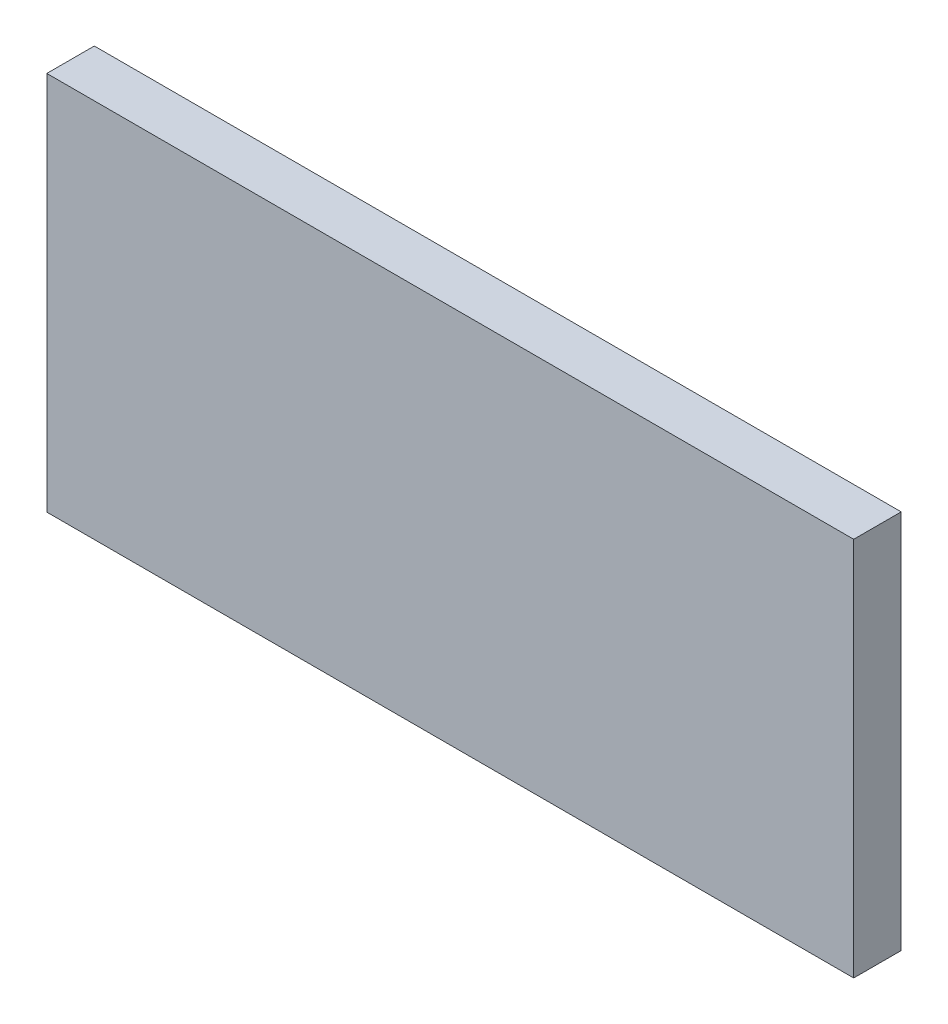
from build123d import *

# Parameters (mm, degrees)
ESBO_O1_W                = 84.948
ESBO_O1_H                = 40
RESSALTO_EXTRUS_O1_DEPTH = 5


with BuildPart() as part:
    # Esboço1 → Ressalto-extrusão1 (new body)
    with BuildSketch(Plane.XY):
        with Locations((0.349214465, -6.720732394)):
            Rectangle(ESBO_O1_W, ESBO_O1_H)
    extrude(amount=RESSALTO_EXTRUS_O1_DEPTH)


solid = part.part
